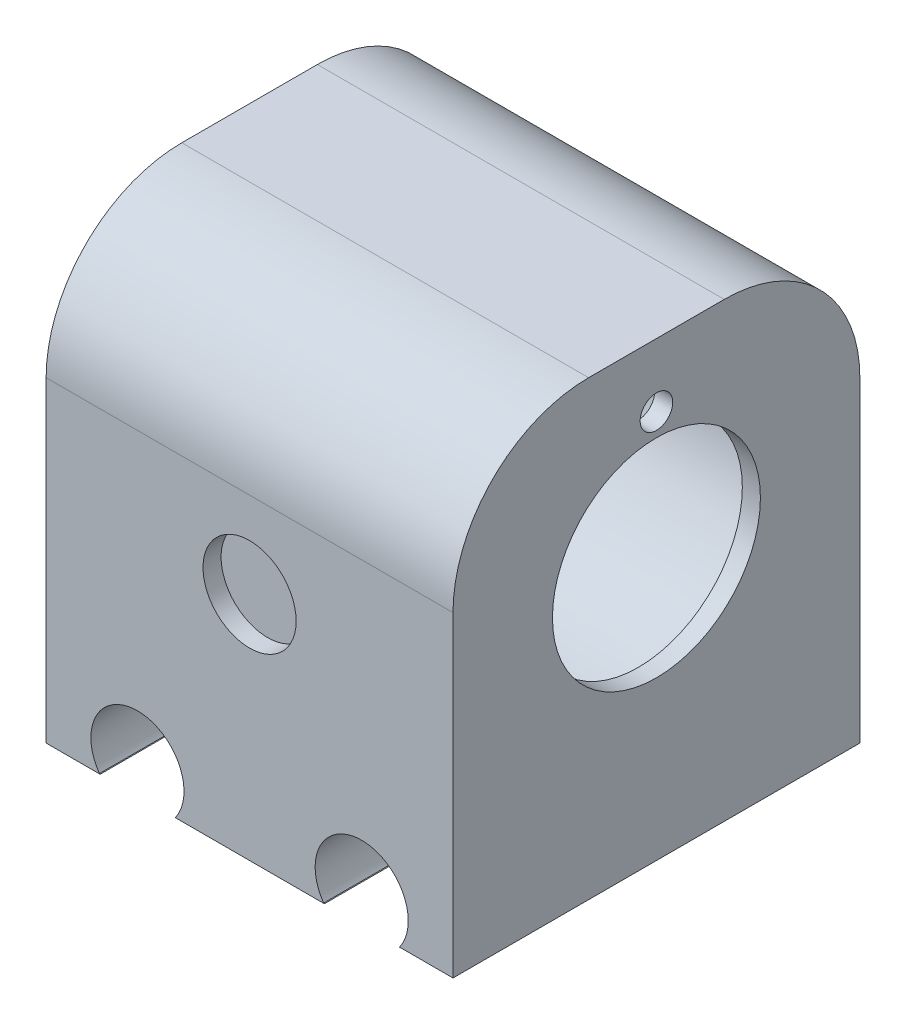
from build123d import *

# Parameters (mm, degrees)
SKETCH1_W           = 45
SKETCH1_H           = 50
BOSS_EXTRUDE1_DEPTH = 45
SKETCH2_R           = 5.2
CUT_EXTRUDE1_DEPTH  = 45
SKETCH9_R           = 5.15
CUT_EXTRUDE6_DEPTH  = 2
SKETCH10_R          = 5.15
CUT_EXTRUDE7_DEPTH  = 2
SKETCH12_R          = 18.375
CUT_EXTRUDE8_DEPTH  = 45
SKETCH13_W          = 45
SKETCH13_H          = 6.66747138
CUT_EXTRUDE9_DEPTH  = 46
SKETCH14_W          = 45
SKETCH14_H          = 6.66747138
BOSS_EXTRUDE2_DEPTH = 45
SKETCH15_R          = 18.375
CUT_EXTRUDE10_DEPTH = 45
FILLET1_R           = 15
SKETCH16_R          = 18.375
BOSS_EXTRUDE3_DEPTH = 2
SKETCH17_R          = 11.5
CUT_EXTRUDE11_DEPTH = 2
SKETCH18_R          = 1.8
CUT_EXTRUDE12_DEPTH = 2
BOSS_EXTRUDE4_DEPTH = 45


with BuildPart() as part:
    # Sketch1 → Boss-Extrude1 (new body)
    with BuildSketch(Plane.XY):
        with Locations((8.236607143, -2.901785714)):
            Rectangle(SKETCH1_W, SKETCH1_H)
    extrude(amount=BOSS_EXTRUDE1_DEPTH)

    # Sketch2 → Cut-Extrude1 (cut)
    with BuildSketch(Plane.XY.offset(45)):
        with Locations((-4.163392857, -24.901785714)):
            Circle(SKETCH2_R)
        with Locations((20.636607143, -24.901785714)):
            Circle(SKETCH2_R)
    extrude(amount=-CUT_EXTRUDE1_DEPTH, mode=Mode.SUBTRACT)

    # Sketch9 → Cut-Extrude6 (cut)
    with BuildSketch(Plane.XY.offset(45)):
        with Locations((8.236607143, -2.401785714)):
            Circle(SKETCH9_R)
    extrude(amount=-CUT_EXTRUDE6_DEPTH, mode=Mode.SUBTRACT)

    # Sketch10 → Cut-Extrude7 (cut)
    with BuildSketch(Plane(origin=(0, 0, 0), x_dir=(-1, 0, 0), z_dir=(0, 0, -1))):
        with Locations((-8.236607143, -2.401785714)):
            Circle(SKETCH10_R)
    extrude(amount=-CUT_EXTRUDE7_DEPTH, mode=Mode.SUBTRACT)

    # Sketch12 → Cut-Extrude8 (cut)
    with BuildSketch(Plane.ZY.offset(14.263392857)):
        with Locations((22.5, 1.098214286)):
            Circle(SKETCH12_R)
    extrude(amount=-CUT_EXTRUDE8_DEPTH, mode=Mode.SUBTRACT)

    # Sketch13 → Cut-Extrude9 (cut)
    with BuildSketch(Plane.ZY.offset(14.263392857)):
        with Locations((22.5, 18.764478596)):
            Rectangle(SKETCH13_W, SKETCH13_H)
    extrude(amount=-CUT_EXTRUDE9_DEPTH, mode=Mode.SUBTRACT)

    # Sketch14 → Boss-Extrude2 (add)
    with BuildSketch(Plane.ZY.offset(14.263392857)):
        with Locations((22.5, 18.764478596)):
            Rectangle(SKETCH14_W, SKETCH14_H)
    extrude(amount=-BOSS_EXTRUDE2_DEPTH)

    # Sketch15 → Cut-Extrude10 (cut)
    with BuildSketch(Plane.ZY.offset(14.263392857)):
        with Locations((22.5, 1.098214286)):
            Circle(SKETCH15_R)
    extrude(amount=-CUT_EXTRUDE10_DEPTH, mode=Mode.SUBTRACT)

    # Fillet1
    fillet1_edges = [part.edges().sort_by_distance(p)[0] for p in [
        (8.236607143, 22.098214286, 0),
        (8.236607143, 22.098214286, 45),
    ]]
    fillet(fillet1_edges, radius=FILLET1_R)

    # Sketch16 → Boss-Extrude3 (add)
    with BuildSketch(Plane(origin=(30.736607143, 0, 0), x_dir=(0, 0, -1), z_dir=(1, 0, 0))):
        with Locations((-22.5, 1.098214286)):
            Circle(SKETCH16_R)
    extrude(amount=-BOSS_EXTRUDE3_DEPTH)

    # Sketch17 → Cut-Extrude11 (cut)
    with BuildSketch(Plane(origin=(30.736607143, 0, 0), x_dir=(0, 0, -1), z_dir=(1, 0, 0))):
        with Locations((-22.5, 1.098214286)):
            Circle(SKETCH17_R)
    extrude(amount=-CUT_EXTRUDE11_DEPTH, mode=Mode.SUBTRACT)

    # Sketch18 → Cut-Extrude12 (cut)
    with BuildSketch(Plane(origin=(30.736607143, 0, 0), x_dir=(0, 0, -1), z_dir=(1, 0, 0))):
        with Locations((-22.5, 15.098214286)):
            Circle(SKETCH18_R)
    extrude(amount=-CUT_EXTRUDE12_DEPTH, mode=Mode.SUBTRACT)

    # Sketch19 → Boss-Extrude4 (add)
    with BuildSketch(Plane.XY.offset(45)):
        with BuildLine():
            Line((0.043119335, -27.87293956), (0.02274465, -27.901785714))
            Line((0.02274465, -27.901785714), (0.083959259, -27.901785714))
            ThreePointArc((0.083959259, -27.901785714), (-4.163392857, -19.701785714), (-8.410744973, -27.901785714))
            Line((-8.410744973, -27.901785714), (-8.286832824, -27.901785714))
            Line((-8.286832824, -27.901785714), (-8.369905049, -27.87293956))
            ThreePointArc((-8.369905049, -27.87293956), (-4.163392857, -19.751785714), (0.043119335, -27.87293956))
        make_face()
        with BuildLine():
            Line((16.430094951, -27.87293956), (16.516624547, -27.901785714))
            Line((16.516624547, -27.901785714), (16.389255027, -27.901785714))
            ThreePointArc((16.389255027, -27.901785714), (20.636607143, -19.701785714), (24.883959259, -27.901785714))
            Line((24.883959259, -27.901785714), (24.82274465, -27.901785714))
            Line((24.82274465, -27.901785714), (24.843119335, -27.87293956))
            ThreePointArc((24.843119335, -27.87293956), (20.636607143, -19.751785714), (16.430094951, -27.87293956))
        make_face()
    extrude(amount=-BOSS_EXTRUDE4_DEPTH)


solid = part.part
